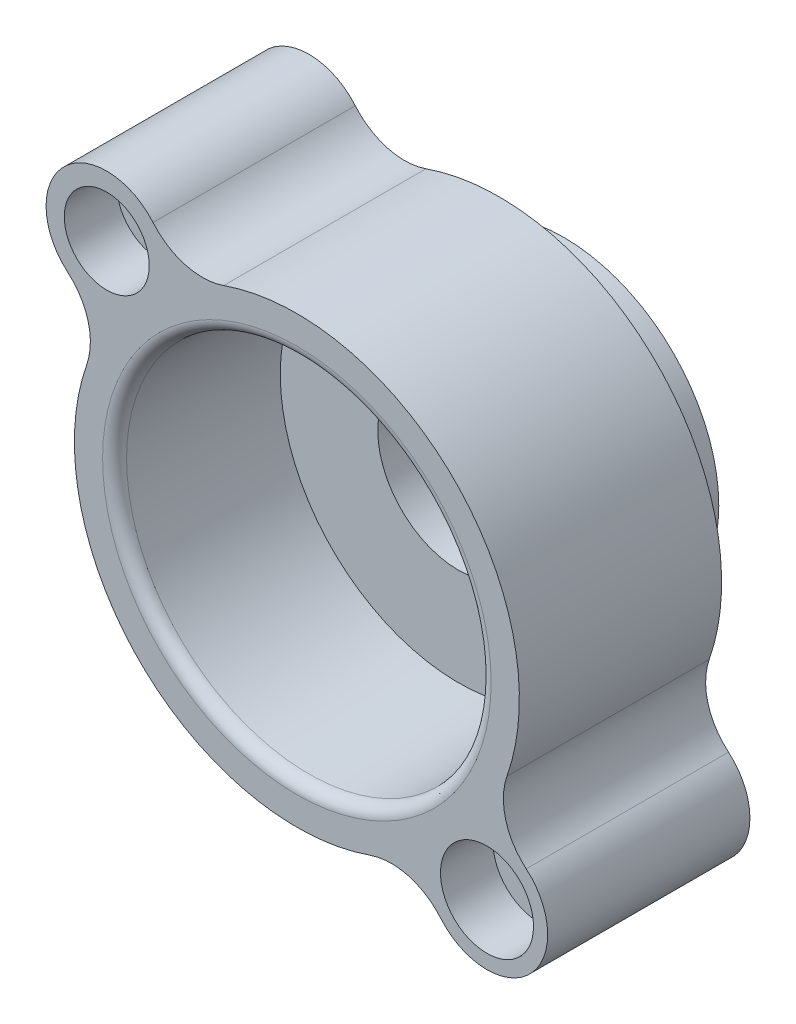
from build123d import *

# Parameters (mm, degrees)
BOSS_EXTRU_1_DEPTH      = 635
ESQUISSE2_R             = 486.41
BOSS_EXTRU_2_DEPTH      = 203.2
ESQUISSE3_R             = 572.77
ENL_V_MAT_EXTRU_1_DEPTH = 508
ENL_V_MAT_EXTRU_1_TAPER = 1.432096184
ESQUISSE4_R             = 254
ENL_V_MAT_EXTRU_2_DEPTH = 331.2
PER_AGE1_D              = 139.7
PER_AGE1_DEPTH          = 838.2
PER_AGE1_CBORE_D        = 292.1
PER_AGE1_CBORE_DEPTH    = 165.1
PER_AGE2_D              = 139.7
PER_AGE2_DEPTH          = 838.2
PER_AGE2_CBORE_D        = 266.7
PER_AGE2_CBORE_DEPTH    = 165.1
CONG_1_R                = 38.1


with BuildPart() as part:
    # Esquisse1 → Boss.-Extru.1 (new body)
    with BuildSketch(Plane.XY.offset(838.2)):
        with BuildLine():
            ThreePointArc((-229.773752251, 659.625858177), (-350.063866609, 655.471932336), (-451.601786597, 720.101782381))
            ThreePointArc((-451.601786597, 720.101782381), (-731.603841816, 731.603841816), (-720.101782381, 451.601786597))
            ThreePointArc((-720.101782381, 451.601786597), (-655.471932336, 350.063866609), (-659.625858178, 229.773752251))
            ThreePointArc((-659.625858178, 229.773752251), (-493.914086659, -493.914086659), (229.773752251, -659.625858178))
            ThreePointArc((229.773752251, -659.625858178), (350.063866609, -655.471932336), (451.601786596, -720.101782381))
            ThreePointArc((451.601786596, -720.101782381), (731.603841816, -731.603841816), (720.101782381, -451.601786596))
            ThreePointArc((720.101782381, -451.601786596), (655.471932336, -350.063866609), (659.625858178, -229.773752251))
            ThreePointArc((659.625858178, -229.773752251), (493.914086659, 493.914086659), (-229.773752251, 659.625858177))
        make_face()
    extrude(amount=-BOSS_EXTRU_1_DEPTH)

    # Esquisse2 → Boss.-Extru.2 (add)
    with BuildSketch(Plane(origin=(0, 0, 203.2), x_dir=(-1, 0, 0), z_dir=(0, 0, -1))):
        Circle(ESQUISSE2_R)
    extrude(amount=BOSS_EXTRU_2_DEPTH)

    # Esquisse3 → Enlèv. mat.-Extru.1 (cut)
    with BuildSketch(Plane.XY.offset(838.2)):
        Circle(ESQUISSE3_R)
    extrude(amount=-ENL_V_MAT_EXTRU_1_DEPTH, taper=ENL_V_MAT_EXTRU_1_TAPER, mode=Mode.SUBTRACT)

    # Esquisse4 → Enlèv. mat.-Extru.2 (cut, through all)
    with BuildSketch(Plane.XY.offset(330.2)):
        Circle(ESQUISSE4_R)
    extrude(amount=-ENL_V_MAT_EXTRU_2_DEPTH, mode=Mode.SUBTRACT)

    # Perçage1
    with Locations(Plane.XY.offset(838.2)):
        with Locations((596.9, -596.9)):
            CounterBoreHole(PER_AGE1_D / 2, PER_AGE1_CBORE_D / 2, PER_AGE1_CBORE_DEPTH, depth=PER_AGE1_DEPTH)

    # Perçage2
    with Locations(Plane.XY.offset(838.2)):
        with Locations((-596.9, 596.9)):
            CounterBoreHole(PER_AGE2_D / 2, PER_AGE2_CBORE_D / 2, PER_AGE2_CBORE_DEPTH, depth=PER_AGE2_DEPTH)

    # Congé1
    cong_1_edges = [part.edges().sort_by_distance(p)[0] for p in [
        (-572.77, 0, 838.2),
    ]]
    fillet(cong_1_edges, radius=CONG_1_R)


solid = part.part
